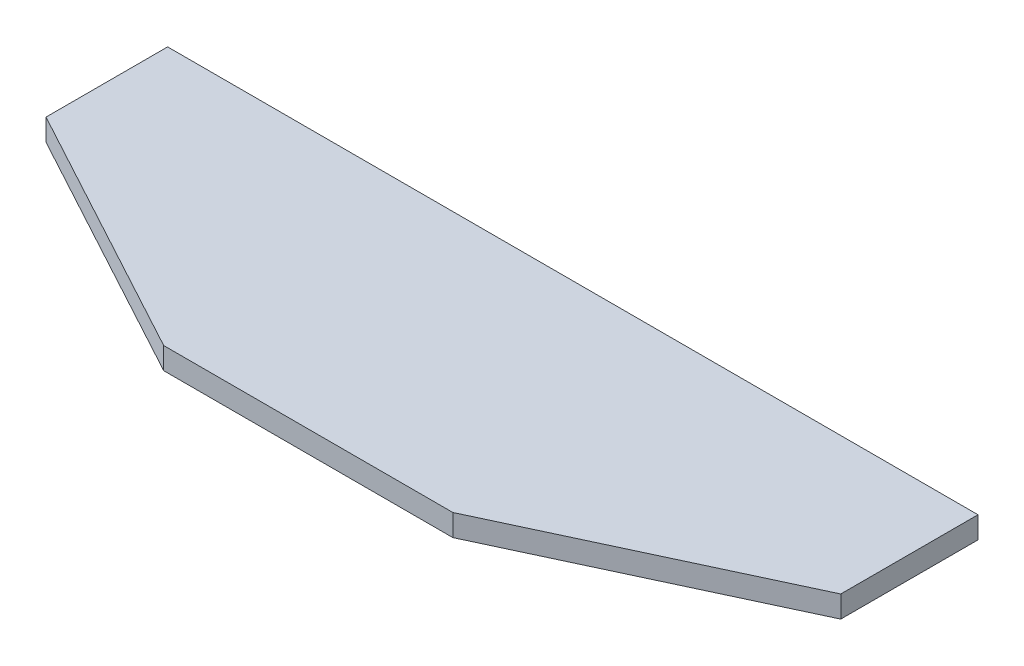
from build123d import *

# Parameters (mm, degrees)
SALIENTE_EXTRUIR1_DEPTH = 5


with BuildPart() as part:
    # Croquis1 → Saliente-Extruir1 (new body)
    with BuildSketch(Plane(origin=(0, 0, 0), x_dir=(1, 0, 0), z_dir=(0, 1, 0))):
        Polygon((-34.081412598, -32.315423537), (32.277378269, -32.315423537), (93, -4), (93, 27.5), (-93, 27.5), (-93, -0.415579359), align=None)
    extrude(amount=SALIENTE_EXTRUIR1_DEPTH)


solid = part.part
